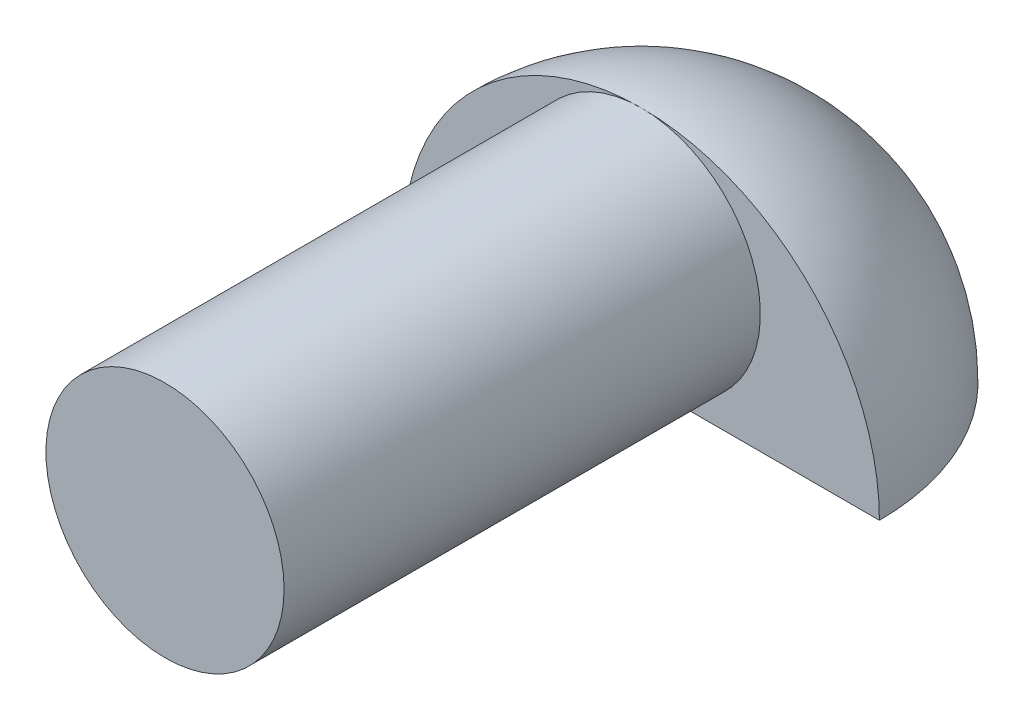
from build123d import *

# Parameters (mm, degrees)
REVOLVE2_ANGLE      = 180
SKETCH8_R           = 9.525
BOSS_EXTRUDE4_DEPTH = 38.1


with BuildPart() as part:
    # Sketch7 → Revolve2 (revolve)
    with BuildSketch(Plane.XY):
        with BuildLine():
            Line((-19.05, 0), (0, 0))
            Line((0, 0), (0, 19.05))
            ThreePointArc((0, 19.05), (-13.470384182, 13.470384182), (-19.05, 0))
        make_face()
    revolve(axis=Axis((0, 19.05, 0), (0, -1, 0)), revolution_arc=REVOLVE2_ANGLE)

    # Sketch8 → Boss-Extrude4 (add)
    with BuildSketch(Plane.XY):
        with Locations((0, 9.525)):
            Circle(SKETCH8_R)
    extrude(amount=BOSS_EXTRUDE4_DEPTH)


solid = part.part
